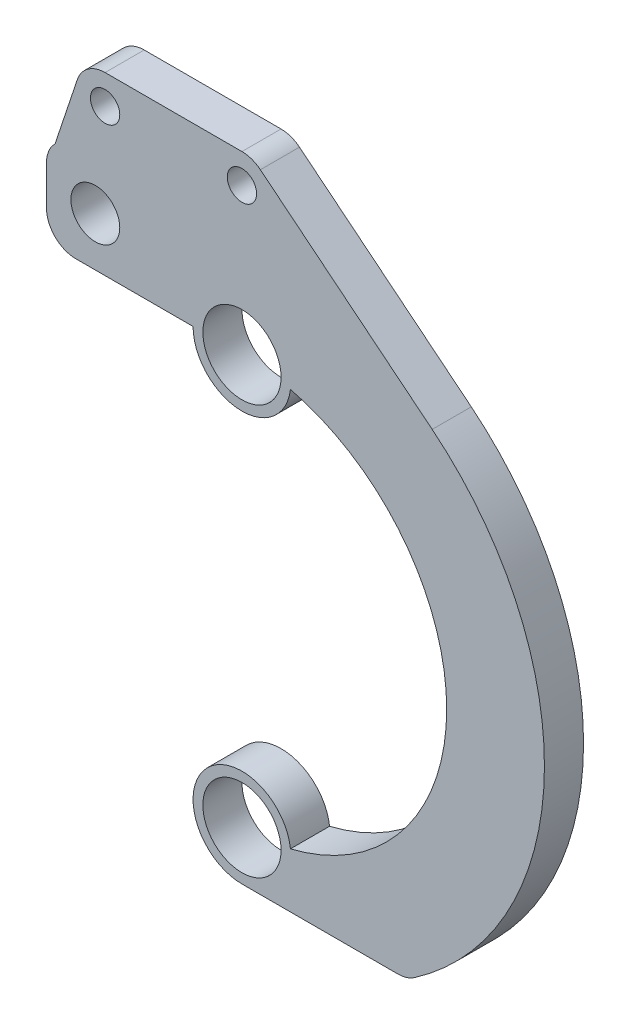
from build123d import *

# Parameters (mm, degrees)
CROQUIS1_R              = 4
CROQUIS1_R_2            = 2.5
CROQUIS1_R_3            = 1.5
SALIENTE_EXTRUIR1_DEPTH = 4


with BuildPart() as part:
    # Croquis1 → Saliente-Extruir1 (new body)
    with BuildSketch(Plane.XY):
        with BuildLine():
            ThreePointArc((17.665369851, -25.41332737), (30.929543207, -1.1251031), (19.465124293, 24.062656467))
            Line((19.465124293, 24.062656467), (1.886764875, 38.28240612))
            ThreePointArc((1.886764875, 38.28240612), (1.000695169, 38.778181249), (0, 38.95))
            Line((0, 38.95), (-14, 38.95))
            ThreePointArc((-14, 38.95), (-15.75421382, 38.383666755), (-16.84611457, 36.898489248))
            Line((-16.84611457, 36.898489248), (-19.121320344, 30.071320344))
            ThreePointArc((-19.121320344, 30.071320344), (-19.771638598, 29.098050297), (-20, 27.95))
            Line((-20, 27.95), (-20, 23.95))
            ThreePointArc((-20, 23.95), (-19.121320344, 21.828679656), (-17, 20.95))
            Line((-17, 20.95), (-5, 20.95))
            ThreePointArc((-5, 20.95), (-0.298863721, 15.958939945), (4.964272191, 20.353341289))
            ThreePointArc((4.964272191, 20.353341289), (20.95, 0), (4.964272191, -20.353341289))
            ThreePointArc((4.964272191, -20.353341289), (-3.740540974, -17.632116153), (0, -25.95))
            Line((0, -25.95), (15.953056134, -25.95))
            ThreePointArc((15.953056134, -25.95), (16.85027904, -25.812689479), (17.665369851, -25.41332737))
        make_face()
        with Locations((0, -20.95)):
            Circle(CROQUIS1_R, mode=Mode.SUBTRACT)
        with Locations((0, 20.95)):
            Circle(CROQUIS1_R, mode=Mode.SUBTRACT)
        with Locations((-15, 25.95)):
            Circle(CROQUIS1_R_2, mode=Mode.SUBTRACT)
        with Locations((0, 35.95)):
            Circle(CROQUIS1_R_3, mode=Mode.SUBTRACT)
        with Locations((-14, 35.95)):
            Circle(CROQUIS1_R_3, mode=Mode.SUBTRACT)
    extrude(amount=SALIENTE_EXTRUIR1_DEPTH)


solid = part.part
